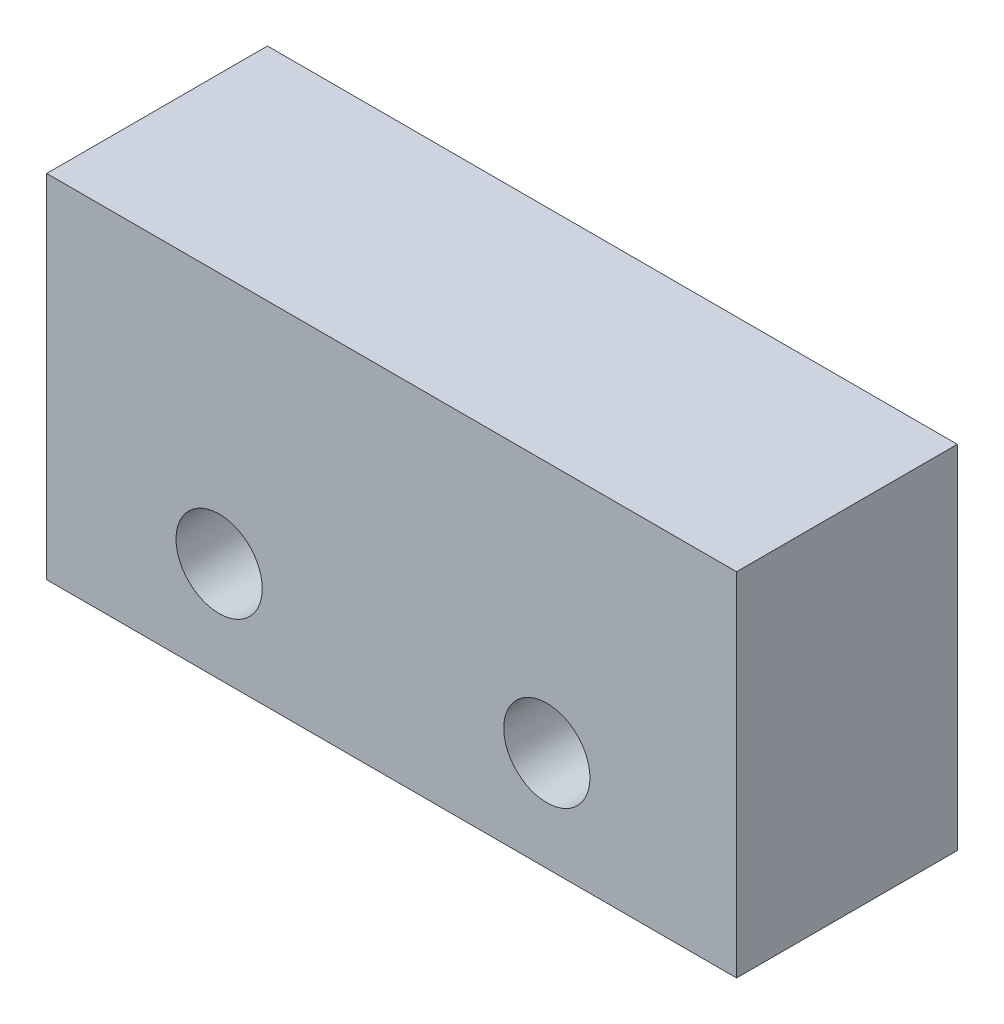
from build123d import *

# Parameters (mm, degrees)
SKETCH1_W           = 20
SKETCH1_H           = 10.2
BOSS_EXTRUDE1_DEPTH = 3.2
SKETCH3_R           = 1.25
CUT_EXTRUDE1_DEPTH  = 7.4


with BuildPart() as part:
    # Sketch1 → Boss-Extrude1 (new body, symmetric)
    with BuildSketch(Plane.XY):
        Rectangle(SKETCH1_W, SKETCH1_H)
    extrude(amount=BOSS_EXTRUDE1_DEPTH, both=True)

    # Sketch3 → Cut-Extrude1 (cut, through all)
    with BuildSketch(Plane.XY.offset(3.2)):
        with Locations((4.5, -2.2)):
            Circle(SKETCH3_R)
        with Locations((-5, -2.2)):
            Circle(SKETCH3_R)
    extrude(amount=-CUT_EXTRUDE1_DEPTH, mode=Mode.SUBTRACT)


solid = part.part
